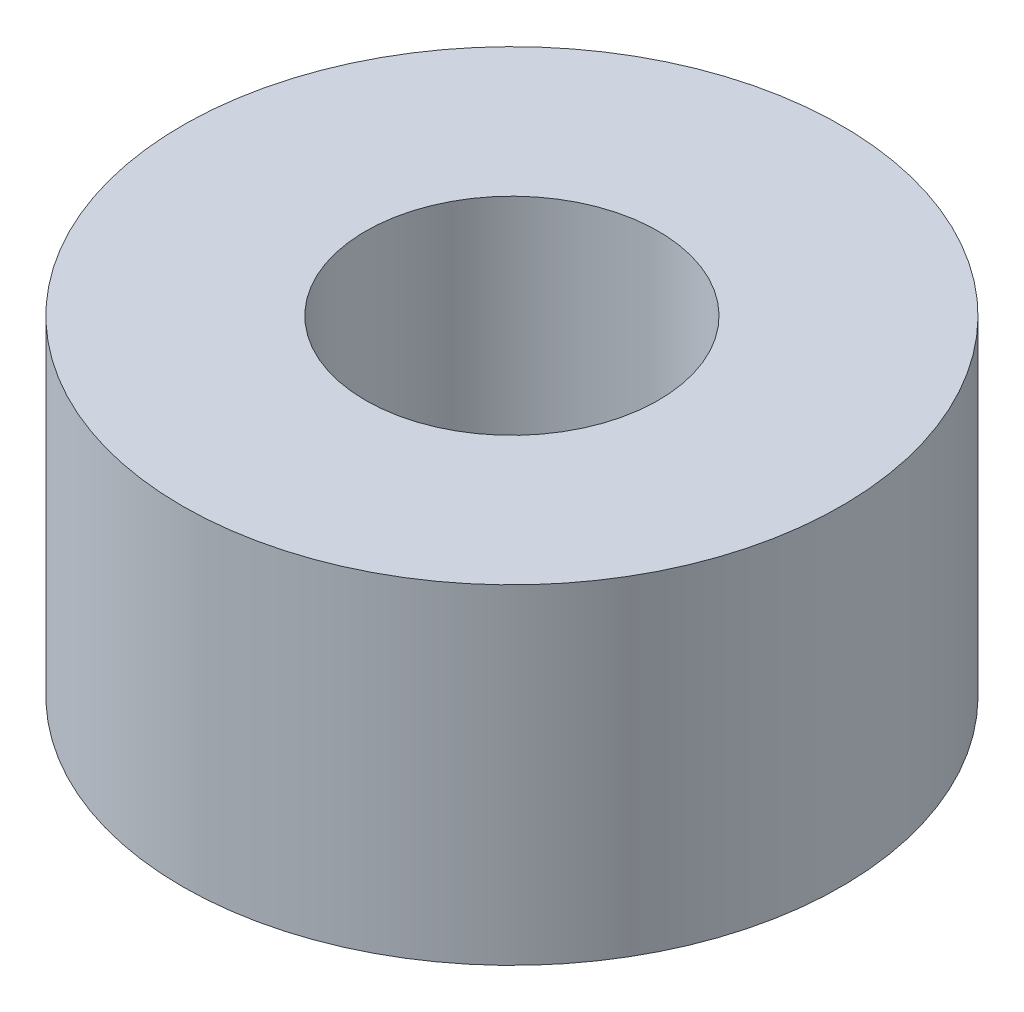
from build123d import *

# Parameters (mm, degrees)
SKETCH2_R           = 4.5
SKETCH2_R_2         = 2
BOSS_EXTRUDE1_DEPTH = 4.5


with BuildPart() as part:
    # Sketch2 → Boss-Extrude1 (new body)
    with BuildSketch(Plane(origin=(0, 0, 0), x_dir=(1, 0, 0), z_dir=(0, 1, 0))):
        Circle(SKETCH2_R)
        Circle(SKETCH2_R_2, mode=Mode.SUBTRACT)
    extrude(amount=BOSS_EXTRUDE1_DEPTH)


solid = part.part
